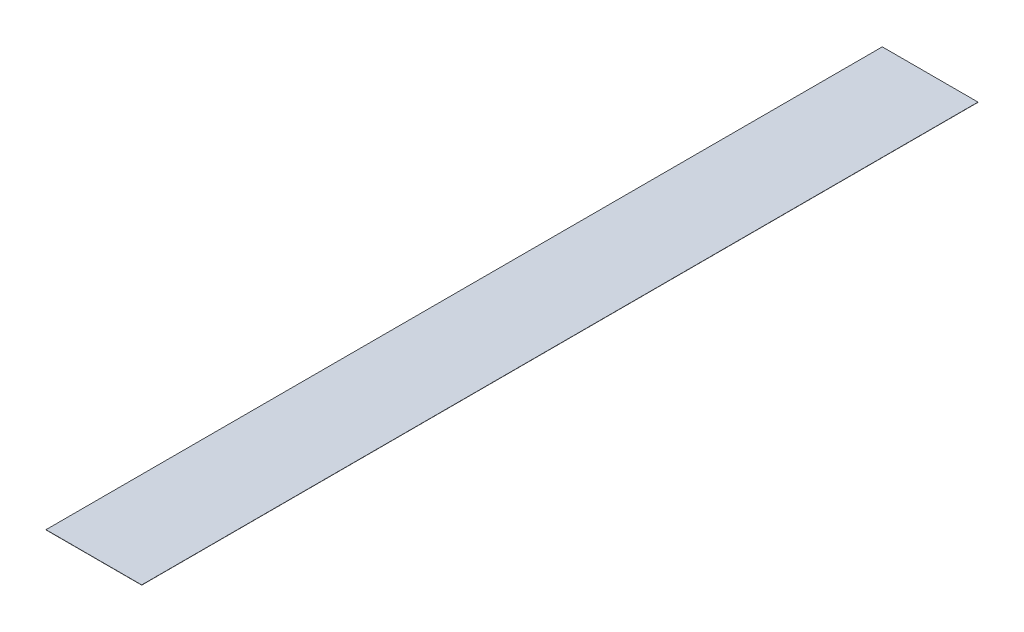
from build123d import *

# Parameters (mm, degrees)
SKETCH1_W      = 23.23
SKETCH1_H      = 202.99
EXTRUDE1_DEPTH = 0.0508


with BuildPart() as part:
    # Sketch1 → Extrude1 (new body)
    with BuildSketch(Plane(origin=(0, 0, 0), x_dir=(1, 0, 0), z_dir=(0, 1, 0))):
        Rectangle(SKETCH1_W, SKETCH1_H)
    extrude(amount=EXTRUDE1_DEPTH)


solid = part.part
